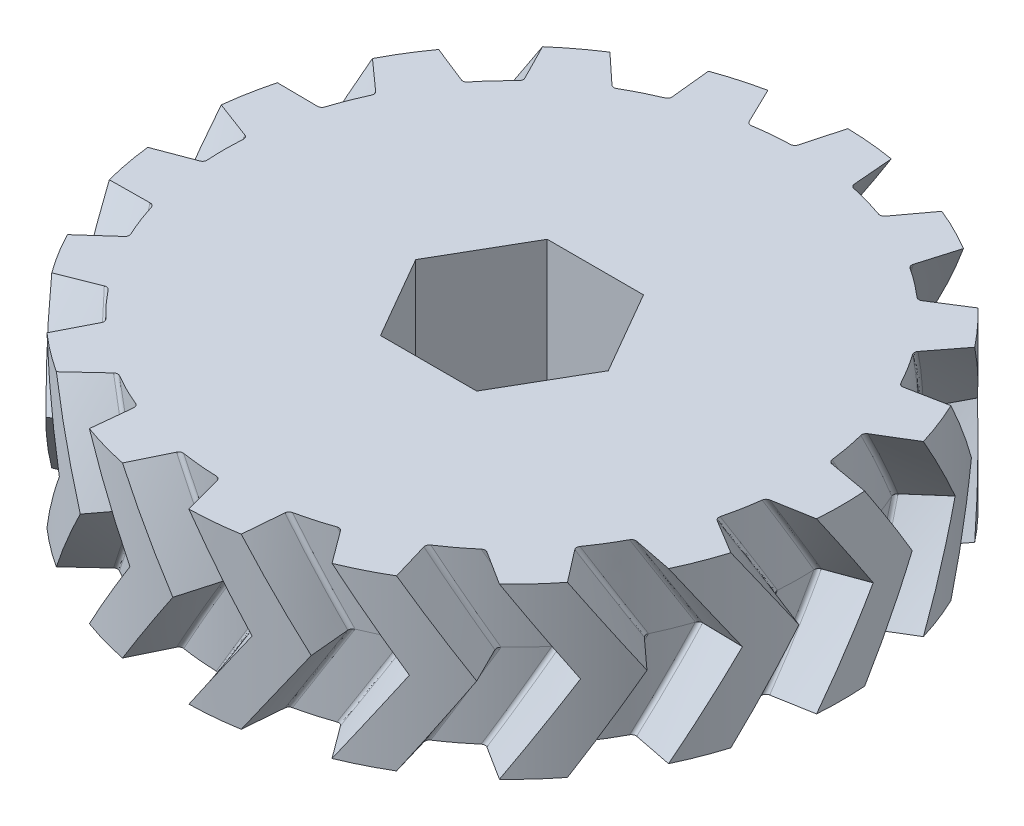
from build123d import *

# Parameters (mm, degrees)
SKETCH1_R                   = 14.625
BOSS_EXTRUDE1_DEPTH         = 3.75
CUT_SWEEP2_PITCH            = 135
CUT_SWEEP2_HEIGHT           = 3.753
CUT_SWEEP2_RADIUS           = 14.25
CUT_SWEEP2_START_ANGLE      = -90
CIRPATTERN1_COUNT           = 17
MIRROR2_COPY_1_PITCH        = 135
MIRROR2_COPY_1_HEIGHT       = 3.753
MIRROR2_COPY_1_RADIUS       = 14.25
MIRROR2_COPY_1_START_ANGLE  = -111.176470588
MIRROR2_COPY_2_PITCH        = 135
MIRROR2_COPY_2_HEIGHT       = 3.753
MIRROR2_COPY_2_RADIUS       = 14.25
MIRROR2_COPY_2_START_ANGLE  = -132.352941176
MIRROR2_COPY_3_PITCH        = 135
MIRROR2_COPY_3_HEIGHT       = 3.753
MIRROR2_COPY_3_RADIUS       = 14.25
MIRROR2_COPY_3_START_ANGLE  = -153.529411765
MIRROR2_COPY_4_PITCH        = 135
MIRROR2_COPY_4_HEIGHT       = 3.753
MIRROR2_COPY_4_RADIUS       = 14.25
MIRROR2_COPY_4_START_ANGLE  = -174.705882353
MIRROR2_COPY_5_PITCH        = 135
MIRROR2_COPY_5_HEIGHT       = 3.753
MIRROR2_COPY_5_RADIUS       = 14.25
MIRROR2_COPY_5_START_ANGLE  = 164.117647059
MIRROR2_COPY_6_PITCH        = 135
MIRROR2_COPY_6_HEIGHT       = 3.753
MIRROR2_COPY_6_RADIUS       = 14.25
MIRROR2_COPY_6_START_ANGLE  = 142.941176471
MIRROR2_COPY_7_PITCH        = 135
MIRROR2_COPY_7_HEIGHT       = 3.753
MIRROR2_COPY_7_RADIUS       = 14.25
MIRROR2_COPY_7_START_ANGLE  = 121.764705882
MIRROR2_COPY_8_PITCH        = 135
MIRROR2_COPY_8_HEIGHT       = 3.753
MIRROR2_COPY_8_RADIUS       = 14.25
MIRROR2_COPY_8_START_ANGLE  = 100.588235294
MIRROR2_COPY_9_PITCH        = 135
MIRROR2_COPY_9_HEIGHT       = 3.753
MIRROR2_COPY_9_RADIUS       = 14.25
MIRROR2_COPY_9_START_ANGLE  = 79.411764706
MIRROR2_COPY_10_PITCH       = 135
MIRROR2_COPY_10_HEIGHT      = 3.753
MIRROR2_COPY_10_RADIUS      = 14.25
MIRROR2_COPY_10_START_ANGLE = 58.235294118
MIRROR2_COPY_11_PITCH       = 135
MIRROR2_COPY_11_HEIGHT      = 3.753
MIRROR2_COPY_11_RADIUS      = 14.25
MIRROR2_COPY_11_START_ANGLE = 37.058823529
MIRROR2_COPY_12_PITCH       = 135
MIRROR2_COPY_12_HEIGHT      = 3.753
MIRROR2_COPY_12_RADIUS      = 14.25
MIRROR2_COPY_12_START_ANGLE = 15.882352941
MIRROR2_COPY_13_PITCH       = 135
MIRROR2_COPY_13_HEIGHT      = 3.753
MIRROR2_COPY_13_RADIUS      = 14.25
MIRROR2_COPY_13_START_ANGLE = -5.294117647
MIRROR2_COPY_14_PITCH       = 135
MIRROR2_COPY_14_HEIGHT      = 3.753
MIRROR2_COPY_14_RADIUS      = 14.25
MIRROR2_COPY_14_START_ANGLE = -26.470588235
MIRROR2_COPY_15_PITCH       = 135
MIRROR2_COPY_15_HEIGHT      = 3.753
MIRROR2_COPY_15_RADIUS      = 14.25
MIRROR2_COPY_15_START_ANGLE = -47.647058824
MIRROR2_COPY_16_PITCH       = 135
MIRROR2_COPY_16_HEIGHT      = 3.753
MIRROR2_COPY_16_RADIUS      = 14.25
MIRROR2_COPY_16_START_ANGLE = -68.823529412


with BuildPart() as part:
    # Sketch1 → Boss-Extrude1 (new body)
    with BuildSketch(Plane(origin=(0, 0, 0), x_dir=(1, 0, 0), z_dir=(0, 1, 0))):
        Circle(SKETCH1_R)
        Polygon((4.272391992, 0), (2.136195996, 3.7), (-2.136195996, 3.7), (-4.272391992, 0), (-2.136195996, -3.7), (2.136195996, -3.7), align=None, mode=Mode.SUBTRACT)
    boss_extrude1 = extrude(amount=BOSS_EXTRUDE1_DEPTH)

    # Cut-Sweep2: sweep along a helix
    with BuildLine() as cut_sweep2_path:
        add(Helix(CUT_SWEEP2_PITCH, CUT_SWEEP2_HEIGHT, CUT_SWEEP2_RADIUS, center=(0, 0, 0), direction=(0, 1, 0), mode=Mode.PRIVATE).rotate(Axis((0, 0, 0), (0, 1, 0)), CUT_SWEEP2_START_ANGLE))
    # Sketch10 → Cut-Sweep2 (sweep, cut)
    with BuildSketch(Plane.XZ):
        with BuildLine():
            Line((-12.854125843, 0.998300796), (-14.561407344, 1.640846144))
            ThreePointArc((-14.561407344, 1.640846144), (-14.850312666, 1.783401649), (-15.025311557, 2.053889626))
            Line((-15.025311557, 2.053889626), (-15.025311557, -2.053889626))
            ThreePointArc((-15.025311557, -2.053889626), (-14.850312666, -1.783401649), (-14.561407344, -1.640846144))
            Line((-14.561407344, -1.640846144), (-12.854125843, -0.998300796))
            ThreePointArc((-12.854125843, -0.998300796), (-12.756634626, -0.919731186), (-12.724965676, -0.798591603))
            ThreePointArc((-12.724965676, -0.798591603), (-12.75, 0), (-12.724965676, 0.798591603))
            ThreePointArc((-12.724965676, 0.798591603), (-12.756634626, 0.919731186), (-12.854125843, 0.998300796))
        make_face()
    cut_sweep2 = sweep(path=cut_sweep2_path.line, is_frenet=True, mode=Mode.SUBTRACT)

    # CirPattern1: Cut-Sweep2 ×17 about axis
    cirpattern1_axis = Axis((0, 3.75, 0), (0, 1, 0))
    for i in range(1, CIRPATTERN1_COUNT):
        add(cut_sweep2.rotate(cirpattern1_axis, i * 360 / CIRPATTERN1_COUNT), mode=Mode.SUBTRACT)

    # Mirror2: Boss-Extrude1, Cut-Sweep2 across plane
    add(boss_extrude1.mirror(Plane.ZX.offset(3.75)))
    add(cut_sweep2.mirror(Plane.ZX.offset(3.75)), mode=Mode.SUBTRACT)

    # Mirror2 copy 1: sweep along a helix
    with BuildLine() as mirror2_copy_1_path:
        add(Helix(MIRROR2_COPY_1_PITCH, MIRROR2_COPY_1_HEIGHT, MIRROR2_COPY_1_RADIUS, center=(0, 7.5, 0), direction=(0, -1, 0), lefthand=True, mode=Mode.PRIVATE).rotate(Axis((0, 7.5, 0), (0, -1, 0)), MIRROR2_COPY_1_START_ANGLE))
    # Mirror2 copy 1 sketch → Mirror2 copy 1 (sweep, cut)
    with BuildSketch(Plane(origin=(0, 7.5, 0), x_dir=(0.932472229, 0, -0.361241666), z_dir=(0, 1, 0))):
        with BuildLine():
            Line((-12.854125843, -0.998300796), (-14.561407344, -1.640846144))
            ThreePointArc((-14.561407344, -1.640846144), (-14.850312666, -1.783401649), (-15.025311557, -2.053889626))
            Line((-15.025311557, -2.053889626), (-15.025311557, 2.053889626))
            ThreePointArc((-15.025311557, 2.053889626), (-14.850312666, 1.783401649), (-14.561407344, 1.640846144))
            Line((-14.561407344, 1.640846144), (-12.854125843, 0.998300796))
            ThreePointArc((-12.854125843, 0.998300796), (-12.756634626, 0.919731186), (-12.724965676, 0.798591603))
            ThreePointArc((-12.724965676, 0.798591603), (-12.75, 0), (-12.724965676, -0.798591603))
            ThreePointArc((-12.724965676, -0.798591603), (-12.756634626, -0.919731186), (-12.854125843, -0.998300796))
        make_face()
    sweep(path=mirror2_copy_1_path.line, is_frenet=True, mode=Mode.SUBTRACT)

    # Mirror2 copy 2: sweep along a helix
    with BuildLine() as mirror2_copy_2_path:
        add(Helix(MIRROR2_COPY_2_PITCH, MIRROR2_COPY_2_HEIGHT, MIRROR2_COPY_2_RADIUS, center=(0, 7.5, 0), direction=(0, -1, 0), lefthand=True, mode=Mode.PRIVATE).rotate(Axis((0, 7.5, 0), (0, -1, 0)), MIRROR2_COPY_2_START_ANGLE))
    # Mirror2 copy 2 sketch → Mirror2 copy 2 (sweep, cut)
    with BuildSketch(Plane(origin=(0, 7.5, 0), x_dir=(0.739008917, 0, -0.673695644), z_dir=(0, 1, 0))):
        with BuildLine():
            Line((-12.854125843, -0.998300796), (-14.561407344, -1.640846144))
            ThreePointArc((-14.561407344, -1.640846144), (-14.850312666, -1.783401649), (-15.025311557, -2.053889626))
            Line((-15.025311557, -2.053889626), (-15.025311557, 2.053889626))
            ThreePointArc((-15.025311557, 2.053889626), (-14.850312666, 1.783401649), (-14.561407344, 1.640846144))
            Line((-14.561407344, 1.640846144), (-12.854125843, 0.998300796))
            ThreePointArc((-12.854125843, 0.998300796), (-12.756634626, 0.919731186), (-12.724965676, 0.798591603))
            ThreePointArc((-12.724965676, 0.798591603), (-12.75, 0), (-12.724965676, -0.798591603))
            ThreePointArc((-12.724965676, -0.798591603), (-12.756634626, -0.919731186), (-12.854125843, -0.998300796))
        make_face()
    sweep(path=mirror2_copy_2_path.line, is_frenet=True, mode=Mode.SUBTRACT)

    # Mirror2 copy 3: sweep along a helix
    with BuildLine() as mirror2_copy_3_path:
        add(Helix(MIRROR2_COPY_3_PITCH, MIRROR2_COPY_3_HEIGHT, MIRROR2_COPY_3_RADIUS, center=(0, 7.5, 0), direction=(0, -1, 0), lefthand=True, mode=Mode.PRIVATE).rotate(Axis((0, 7.5, 0), (0, -1, 0)), MIRROR2_COPY_3_START_ANGLE))
    # Mirror2 copy 3 sketch → Mirror2 copy 3 (sweep, cut)
    with BuildSketch(Plane(origin=(0, 7.5, 0), x_dir=(0.445738356, 0, -0.895163291), z_dir=(0, 1, 0))):
        with BuildLine():
            Line((-12.854125843, -0.998300796), (-14.561407344, -1.640846144))
            ThreePointArc((-14.561407344, -1.640846144), (-14.850312666, -1.783401649), (-15.025311557, -2.053889626))
            Line((-15.025311557, -2.053889626), (-15.025311557, 2.053889626))
            ThreePointArc((-15.025311557, 2.053889626), (-14.850312666, 1.783401649), (-14.561407344, 1.640846144))
            Line((-14.561407344, 1.640846144), (-12.854125843, 0.998300796))
            ThreePointArc((-12.854125843, 0.998300796), (-12.756634626, 0.919731186), (-12.724965676, 0.798591603))
            ThreePointArc((-12.724965676, 0.798591603), (-12.75, 0), (-12.724965676, -0.798591603))
            ThreePointArc((-12.724965676, -0.798591603), (-12.756634626, -0.919731186), (-12.854125843, -0.998300796))
        make_face()
    sweep(path=mirror2_copy_3_path.line, is_frenet=True, mode=Mode.SUBTRACT)

    # Mirror2 copy 4: sweep along a helix
    with BuildLine() as mirror2_copy_4_path:
        add(Helix(MIRROR2_COPY_4_PITCH, MIRROR2_COPY_4_HEIGHT, MIRROR2_COPY_4_RADIUS, center=(0, 7.5, 0), direction=(0, -1, 0), lefthand=True, mode=Mode.PRIVATE).rotate(Axis((0, 7.5, 0), (0, -1, 0)), MIRROR2_COPY_4_START_ANGLE))
    # Mirror2 copy 4 sketch → Mirror2 copy 4 (sweep, cut)
    with BuildSketch(Plane(origin=(0, 7.5, 0), x_dir=(0.092268359, 0, -0.995734176), z_dir=(0, 1, 0))):
        with BuildLine():
            Line((-12.854125843, -0.998300796), (-14.561407344, -1.640846144))
            ThreePointArc((-14.561407344, -1.640846144), (-14.850312666, -1.783401649), (-15.025311557, -2.053889626))
            Line((-15.025311557, -2.053889626), (-15.025311557, 2.053889626))
            ThreePointArc((-15.025311557, 2.053889626), (-14.850312666, 1.783401649), (-14.561407344, 1.640846144))
            Line((-14.561407344, 1.640846144), (-12.854125843, 0.998300796))
            ThreePointArc((-12.854125843, 0.998300796), (-12.756634626, 0.919731186), (-12.724965676, 0.798591603))
            ThreePointArc((-12.724965676, 0.798591603), (-12.75, 0), (-12.724965676, -0.798591603))
            ThreePointArc((-12.724965676, -0.798591603), (-12.756634626, -0.919731186), (-12.854125843, -0.998300796))
        make_face()
    sweep(path=mirror2_copy_4_path.line, is_frenet=True, mode=Mode.SUBTRACT)

    # Mirror2 copy 5: sweep along a helix
    with BuildLine() as mirror2_copy_5_path:
        add(Helix(MIRROR2_COPY_5_PITCH, MIRROR2_COPY_5_HEIGHT, MIRROR2_COPY_5_RADIUS, center=(0, 7.5, 0), direction=(0, -1, 0), lefthand=True, mode=Mode.PRIVATE).rotate(Axis((0, 7.5, 0), (0, -1, 0)), MIRROR2_COPY_5_START_ANGLE))
    # Mirror2 copy 5 sketch → Mirror2 copy 5 (sweep, cut)
    with BuildSketch(Plane(origin=(0, 7.5, 0), x_dir=(-0.27366299, 0, -0.961825643), z_dir=(0, 1, 0))):
        with BuildLine():
            Line((-12.854125843, -0.998300796), (-14.561407344, -1.640846144))
            ThreePointArc((-14.561407344, -1.640846144), (-14.850312666, -1.783401649), (-15.025311557, -2.053889626))
            Line((-15.025311557, -2.053889626), (-15.025311557, 2.053889626))
            ThreePointArc((-15.025311557, 2.053889626), (-14.850312666, 1.783401649), (-14.561407344, 1.640846144))
            Line((-14.561407344, 1.640846144), (-12.854125843, 0.998300796))
            ThreePointArc((-12.854125843, 0.998300796), (-12.756634626, 0.919731186), (-12.724965676, 0.798591603))
            ThreePointArc((-12.724965676, 0.798591603), (-12.75, 0), (-12.724965676, -0.798591603))
            ThreePointArc((-12.724965676, -0.798591603), (-12.756634626, -0.919731186), (-12.854125843, -0.998300796))
        make_face()
    sweep(path=mirror2_copy_5_path.line, is_frenet=True, mode=Mode.SUBTRACT)

    # Mirror2 copy 6: sweep along a helix
    with BuildLine() as mirror2_copy_6_path:
        add(Helix(MIRROR2_COPY_6_PITCH, MIRROR2_COPY_6_HEIGHT, MIRROR2_COPY_6_RADIUS, center=(0, 7.5, 0), direction=(0, -1, 0), lefthand=True, mode=Mode.PRIVATE).rotate(Axis((0, 7.5, 0), (0, -1, 0)), MIRROR2_COPY_6_START_ANGLE))
    # Mirror2 copy 6 sketch → Mirror2 copy 6 (sweep, cut)
    with BuildSketch(Plane(origin=(0, 7.5, 0), x_dir=(-0.602634636, 0, -0.798017227), z_dir=(0, 1, 0))):
        with BuildLine():
            Line((-12.854125843, -0.998300796), (-14.561407344, -1.640846144))
            ThreePointArc((-14.561407344, -1.640846144), (-14.850312666, -1.783401649), (-15.025311557, -2.053889626))
            Line((-15.025311557, -2.053889626), (-15.025311557, 2.053889626))
            ThreePointArc((-15.025311557, 2.053889626), (-14.850312666, 1.783401649), (-14.561407344, 1.640846144))
            Line((-14.561407344, 1.640846144), (-12.854125843, 0.998300796))
            ThreePointArc((-12.854125843, 0.998300796), (-12.756634626, 0.919731186), (-12.724965676, 0.798591603))
            ThreePointArc((-12.724965676, 0.798591603), (-12.75, 0), (-12.724965676, -0.798591603))
            ThreePointArc((-12.724965676, -0.798591603), (-12.756634626, -0.919731186), (-12.854125843, -0.998300796))
        make_face()
    sweep(path=mirror2_copy_6_path.line, is_frenet=True, mode=Mode.SUBTRACT)

    # Mirror2 copy 7: sweep along a helix
    with BuildLine() as mirror2_copy_7_path:
        add(Helix(MIRROR2_COPY_7_PITCH, MIRROR2_COPY_7_HEIGHT, MIRROR2_COPY_7_RADIUS, center=(0, 7.5, 0), direction=(0, -1, 0), lefthand=True, mode=Mode.PRIVATE).rotate(Axis((0, 7.5, 0), (0, -1, 0)), MIRROR2_COPY_7_START_ANGLE))
    # Mirror2 copy 7 sketch → Mirror2 copy 7 (sweep, cut)
    with BuildSketch(Plane(origin=(0, 7.5, 0), x_dir=(-0.850217136, 0, -0.526432163), z_dir=(0, 1, 0))):
        with BuildLine():
            Line((-12.854125843, -0.998300796), (-14.561407344, -1.640846144))
            ThreePointArc((-14.561407344, -1.640846144), (-14.850312666, -1.783401649), (-15.025311557, -2.053889626))
            Line((-15.025311557, -2.053889626), (-15.025311557, 2.053889626))
            ThreePointArc((-15.025311557, 2.053889626), (-14.850312666, 1.783401649), (-14.561407344, 1.640846144))
            Line((-14.561407344, 1.640846144), (-12.854125843, 0.998300796))
            ThreePointArc((-12.854125843, 0.998300796), (-12.756634626, 0.919731186), (-12.724965676, 0.798591603))
            ThreePointArc((-12.724965676, 0.798591603), (-12.75, 0), (-12.724965676, -0.798591603))
            ThreePointArc((-12.724965676, -0.798591603), (-12.756634626, -0.919731186), (-12.854125843, -0.998300796))
        make_face()
    sweep(path=mirror2_copy_7_path.line, is_frenet=True, mode=Mode.SUBTRACT)

    # Mirror2 copy 8: sweep along a helix
    with BuildLine() as mirror2_copy_8_path:
        add(Helix(MIRROR2_COPY_8_PITCH, MIRROR2_COPY_8_HEIGHT, MIRROR2_COPY_8_RADIUS, center=(0, 7.5, 0), direction=(0, -1, 0), lefthand=True, mode=Mode.PRIVATE).rotate(Axis((0, 7.5, 0), (0, -1, 0)), MIRROR2_COPY_8_START_ANGLE))
    # Mirror2 copy 8 sketch → Mirror2 copy 8 (sweep, cut)
    with BuildSketch(Plane(origin=(0, 7.5, 0), x_dir=(-0.9829731, 0, -0.183749518), z_dir=(0, 1, 0))):
        with BuildLine():
            Line((-12.854125843, -0.998300796), (-14.561407344, -1.640846144))
            ThreePointArc((-14.561407344, -1.640846144), (-14.850312666, -1.783401649), (-15.025311557, -2.053889626))
            Line((-15.025311557, -2.053889626), (-15.025311557, 2.053889626))
            ThreePointArc((-15.025311557, 2.053889626), (-14.850312666, 1.783401649), (-14.561407344, 1.640846144))
            Line((-14.561407344, 1.640846144), (-12.854125843, 0.998300796))
            ThreePointArc((-12.854125843, 0.998300796), (-12.756634626, 0.919731186), (-12.724965676, 0.798591603))
            ThreePointArc((-12.724965676, 0.798591603), (-12.75, 0), (-12.724965676, -0.798591603))
            ThreePointArc((-12.724965676, -0.798591603), (-12.756634626, -0.919731186), (-12.854125843, -0.998300796))
        make_face()
    sweep(path=mirror2_copy_8_path.line, is_frenet=True, mode=Mode.SUBTRACT)

    # Mirror2 copy 9: sweep along a helix
    with BuildLine() as mirror2_copy_9_path:
        add(Helix(MIRROR2_COPY_9_PITCH, MIRROR2_COPY_9_HEIGHT, MIRROR2_COPY_9_RADIUS, center=(0, 7.5, 0), direction=(0, -1, 0), lefthand=True, mode=Mode.PRIVATE).rotate(Axis((0, 7.5, 0), (0, -1, 0)), MIRROR2_COPY_9_START_ANGLE))
    # Mirror2 copy 9 sketch → Mirror2 copy 9 (sweep, cut)
    with BuildSketch(Plane(origin=(0, 7.5, 0), x_dir=(-0.9829731, 0, 0.183749518), z_dir=(0, 1, 0))):
        with BuildLine():
            Line((-12.854125843, -0.998300796), (-14.561407344, -1.640846144))
            ThreePointArc((-14.561407344, -1.640846144), (-14.850312666, -1.783401649), (-15.025311557, -2.053889626))
            Line((-15.025311557, -2.053889626), (-15.025311557, 2.053889626))
            ThreePointArc((-15.025311557, 2.053889626), (-14.850312666, 1.783401649), (-14.561407344, 1.640846144))
            Line((-14.561407344, 1.640846144), (-12.854125843, 0.998300796))
            ThreePointArc((-12.854125843, 0.998300796), (-12.756634626, 0.919731186), (-12.724965676, 0.798591603))
            ThreePointArc((-12.724965676, 0.798591603), (-12.75, 0), (-12.724965676, -0.798591603))
            ThreePointArc((-12.724965676, -0.798591603), (-12.756634626, -0.919731186), (-12.854125843, -0.998300796))
        make_face()
    sweep(path=mirror2_copy_9_path.line, is_frenet=True, mode=Mode.SUBTRACT)

    # Mirror2 copy 10: sweep along a helix
    with BuildLine() as mirror2_copy_10_path:
        add(Helix(MIRROR2_COPY_10_PITCH, MIRROR2_COPY_10_HEIGHT, MIRROR2_COPY_10_RADIUS, center=(0, 7.5, 0), direction=(0, -1, 0), lefthand=True, mode=Mode.PRIVATE).rotate(Axis((0, 7.5, 0), (0, -1, 0)), MIRROR2_COPY_10_START_ANGLE))
    # Mirror2 copy 10 sketch → Mirror2 copy 10 (sweep, cut)
    with BuildSketch(Plane(origin=(0, 7.5, 0), x_dir=(-0.850217136, 0, 0.526432163), z_dir=(0, 1, 0))):
        with BuildLine():
            Line((-12.854125843, -0.998300796), (-14.561407344, -1.640846144))
            ThreePointArc((-14.561407344, -1.640846144), (-14.850312666, -1.783401649), (-15.025311557, -2.053889626))
            Line((-15.025311557, -2.053889626), (-15.025311557, 2.053889626))
            ThreePointArc((-15.025311557, 2.053889626), (-14.850312666, 1.783401649), (-14.561407344, 1.640846144))
            Line((-14.561407344, 1.640846144), (-12.854125843, 0.998300796))
            ThreePointArc((-12.854125843, 0.998300796), (-12.756634626, 0.919731186), (-12.724965676, 0.798591603))
            ThreePointArc((-12.724965676, 0.798591603), (-12.75, 0), (-12.724965676, -0.798591603))
            ThreePointArc((-12.724965676, -0.798591603), (-12.756634626, -0.919731186), (-12.854125843, -0.998300796))
        make_face()
    sweep(path=mirror2_copy_10_path.line, is_frenet=True, mode=Mode.SUBTRACT)

    # Mirror2 copy 11: sweep along a helix
    with BuildLine() as mirror2_copy_11_path:
        add(Helix(MIRROR2_COPY_11_PITCH, MIRROR2_COPY_11_HEIGHT, MIRROR2_COPY_11_RADIUS, center=(0, 7.5, 0), direction=(0, -1, 0), lefthand=True, mode=Mode.PRIVATE).rotate(Axis((0, 7.5, 0), (0, -1, 0)), MIRROR2_COPY_11_START_ANGLE))
    # Mirror2 copy 11 sketch → Mirror2 copy 11 (sweep, cut)
    with BuildSketch(Plane(origin=(0, 7.5, 0), x_dir=(-0.602634636, 0, 0.798017227), z_dir=(0, 1, 0))):
        with BuildLine():
            Line((-12.854125843, -0.998300796), (-14.561407344, -1.640846144))
            ThreePointArc((-14.561407344, -1.640846144), (-14.850312666, -1.783401649), (-15.025311557, -2.053889626))
            Line((-15.025311557, -2.053889626), (-15.025311557, 2.053889626))
            ThreePointArc((-15.025311557, 2.053889626), (-14.850312666, 1.783401649), (-14.561407344, 1.640846144))
            Line((-14.561407344, 1.640846144), (-12.854125843, 0.998300796))
            ThreePointArc((-12.854125843, 0.998300796), (-12.756634626, 0.919731186), (-12.724965676, 0.798591603))
            ThreePointArc((-12.724965676, 0.798591603), (-12.75, 0), (-12.724965676, -0.798591603))
            ThreePointArc((-12.724965676, -0.798591603), (-12.756634626, -0.919731186), (-12.854125843, -0.998300796))
        make_face()
    sweep(path=mirror2_copy_11_path.line, is_frenet=True, mode=Mode.SUBTRACT)

    # Mirror2 copy 12: sweep along a helix
    with BuildLine() as mirror2_copy_12_path:
        add(Helix(MIRROR2_COPY_12_PITCH, MIRROR2_COPY_12_HEIGHT, MIRROR2_COPY_12_RADIUS, center=(0, 7.5, 0), direction=(0, -1, 0), lefthand=True, mode=Mode.PRIVATE).rotate(Axis((0, 7.5, 0), (0, -1, 0)), MIRROR2_COPY_12_START_ANGLE))
    # Mirror2 copy 12 sketch → Mirror2 copy 12 (sweep, cut)
    with BuildSketch(Plane(origin=(0, 7.5, 0), x_dir=(-0.27366299, 0, 0.961825643), z_dir=(0, 1, 0))):
        with BuildLine():
            Line((-12.854125843, -0.998300796), (-14.561407344, -1.640846144))
            ThreePointArc((-14.561407344, -1.640846144), (-14.850312666, -1.783401649), (-15.025311557, -2.053889626))
            Line((-15.025311557, -2.053889626), (-15.025311557, 2.053889626))
            ThreePointArc((-15.025311557, 2.053889626), (-14.850312666, 1.783401649), (-14.561407344, 1.640846144))
            Line((-14.561407344, 1.640846144), (-12.854125843, 0.998300796))
            ThreePointArc((-12.854125843, 0.998300796), (-12.756634626, 0.919731186), (-12.724965676, 0.798591603))
            ThreePointArc((-12.724965676, 0.798591603), (-12.75, 0), (-12.724965676, -0.798591603))
            ThreePointArc((-12.724965676, -0.798591603), (-12.756634626, -0.919731186), (-12.854125843, -0.998300796))
        make_face()
    sweep(path=mirror2_copy_12_path.line, is_frenet=True, mode=Mode.SUBTRACT)

    # Mirror2 copy 13: sweep along a helix
    with BuildLine() as mirror2_copy_13_path:
        add(Helix(MIRROR2_COPY_13_PITCH, MIRROR2_COPY_13_HEIGHT, MIRROR2_COPY_13_RADIUS, center=(0, 7.5, 0), direction=(0, -1, 0), lefthand=True, mode=Mode.PRIVATE).rotate(Axis((0, 7.5, 0), (0, -1, 0)), MIRROR2_COPY_13_START_ANGLE))
    # Mirror2 copy 13 sketch → Mirror2 copy 13 (sweep, cut)
    with BuildSketch(Plane(origin=(0, 7.5, 0), x_dir=(0.092268359, 0, 0.995734176), z_dir=(0, 1, 0))):
        with BuildLine():
            Line((-12.854125843, -0.998300796), (-14.561407344, -1.640846144))
            ThreePointArc((-14.561407344, -1.640846144), (-14.850312666, -1.783401649), (-15.025311557, -2.053889626))
            Line((-15.025311557, -2.053889626), (-15.025311557, 2.053889626))
            ThreePointArc((-15.025311557, 2.053889626), (-14.850312666, 1.783401649), (-14.561407344, 1.640846144))
            Line((-14.561407344, 1.640846144), (-12.854125843, 0.998300796))
            ThreePointArc((-12.854125843, 0.998300796), (-12.756634626, 0.919731186), (-12.724965676, 0.798591603))
            ThreePointArc((-12.724965676, 0.798591603), (-12.75, 0), (-12.724965676, -0.798591603))
            ThreePointArc((-12.724965676, -0.798591603), (-12.756634626, -0.919731186), (-12.854125843, -0.998300796))
        make_face()
    sweep(path=mirror2_copy_13_path.line, is_frenet=True, mode=Mode.SUBTRACT)

    # Mirror2 copy 14: sweep along a helix
    with BuildLine() as mirror2_copy_14_path:
        add(Helix(MIRROR2_COPY_14_PITCH, MIRROR2_COPY_14_HEIGHT, MIRROR2_COPY_14_RADIUS, center=(0, 7.5, 0), direction=(0, -1, 0), lefthand=True, mode=Mode.PRIVATE).rotate(Axis((0, 7.5, 0), (0, -1, 0)), MIRROR2_COPY_14_START_ANGLE))
    # Mirror2 copy 14 sketch → Mirror2 copy 14 (sweep, cut)
    with BuildSketch(Plane(origin=(0, 7.5, 0), x_dir=(0.445738356, 0, 0.895163291), z_dir=(0, 1, 0))):
        with BuildLine():
            Line((-12.854125843, -0.998300796), (-14.561407344, -1.640846144))
            ThreePointArc((-14.561407344, -1.640846144), (-14.850312666, -1.783401649), (-15.025311557, -2.053889626))
            Line((-15.025311557, -2.053889626), (-15.025311557, 2.053889626))
            ThreePointArc((-15.025311557, 2.053889626), (-14.850312666, 1.783401649), (-14.561407344, 1.640846144))
            Line((-14.561407344, 1.640846144), (-12.854125843, 0.998300796))
            ThreePointArc((-12.854125843, 0.998300796), (-12.756634626, 0.919731186), (-12.724965676, 0.798591603))
            ThreePointArc((-12.724965676, 0.798591603), (-12.75, 0), (-12.724965676, -0.798591603))
            ThreePointArc((-12.724965676, -0.798591603), (-12.756634626, -0.919731186), (-12.854125843, -0.998300796))
        make_face()
    sweep(path=mirror2_copy_14_path.line, is_frenet=True, mode=Mode.SUBTRACT)

    # Mirror2 copy 15: sweep along a helix
    with BuildLine() as mirror2_copy_15_path:
        add(Helix(MIRROR2_COPY_15_PITCH, MIRROR2_COPY_15_HEIGHT, MIRROR2_COPY_15_RADIUS, center=(0, 7.5, 0), direction=(0, -1, 0), lefthand=True, mode=Mode.PRIVATE).rotate(Axis((0, 7.5, 0), (0, -1, 0)), MIRROR2_COPY_15_START_ANGLE))
    # Mirror2 copy 15 sketch → Mirror2 copy 15 (sweep, cut)
    with BuildSketch(Plane(origin=(0, 7.5, 0), x_dir=(0.739008917, 0, 0.673695644), z_dir=(0, 1, 0))):
        with BuildLine():
            Line((-12.854125843, -0.998300796), (-14.561407344, -1.640846144))
            ThreePointArc((-14.561407344, -1.640846144), (-14.850312666, -1.783401649), (-15.025311557, -2.053889626))
            Line((-15.025311557, -2.053889626), (-15.025311557, 2.053889626))
            ThreePointArc((-15.025311557, 2.053889626), (-14.850312666, 1.783401649), (-14.561407344, 1.640846144))
            Line((-14.561407344, 1.640846144), (-12.854125843, 0.998300796))
            ThreePointArc((-12.854125843, 0.998300796), (-12.756634626, 0.919731186), (-12.724965676, 0.798591603))
            ThreePointArc((-12.724965676, 0.798591603), (-12.75, 0), (-12.724965676, -0.798591603))
            ThreePointArc((-12.724965676, -0.798591603), (-12.756634626, -0.919731186), (-12.854125843, -0.998300796))
        make_face()
    sweep(path=mirror2_copy_15_path.line, is_frenet=True, mode=Mode.SUBTRACT)

    # Mirror2 copy 16: sweep along a helix
    with BuildLine() as mirror2_copy_16_path:
        add(Helix(MIRROR2_COPY_16_PITCH, MIRROR2_COPY_16_HEIGHT, MIRROR2_COPY_16_RADIUS, center=(0, 7.5, 0), direction=(0, -1, 0), lefthand=True, mode=Mode.PRIVATE).rotate(Axis((0, 7.5, 0), (0, -1, 0)), MIRROR2_COPY_16_START_ANGLE))
    # Mirror2 copy 16 sketch → Mirror2 copy 16 (sweep, cut)
    with BuildSketch(Plane(origin=(0, 7.5, 0), x_dir=(0.932472229, 0, 0.361241666), z_dir=(0, 1, 0))):
        with BuildLine():
            Line((-12.854125843, -0.998300796), (-14.561407344, -1.640846144))
            ThreePointArc((-14.561407344, -1.640846144), (-14.850312666, -1.783401649), (-15.025311557, -2.053889626))
            Line((-15.025311557, -2.053889626), (-15.025311557, 2.053889626))
            ThreePointArc((-15.025311557, 2.053889626), (-14.850312666, 1.783401649), (-14.561407344, 1.640846144))
            Line((-14.561407344, 1.640846144), (-12.854125843, 0.998300796))
            ThreePointArc((-12.854125843, 0.998300796), (-12.756634626, 0.919731186), (-12.724965676, 0.798591603))
            ThreePointArc((-12.724965676, 0.798591603), (-12.75, 0), (-12.724965676, -0.798591603))
            ThreePointArc((-12.724965676, -0.798591603), (-12.756634626, -0.919731186), (-12.854125843, -0.998300796))
        make_face()
    sweep(path=mirror2_copy_16_path.line, is_frenet=True, mode=Mode.SUBTRACT)


solid = part.part
